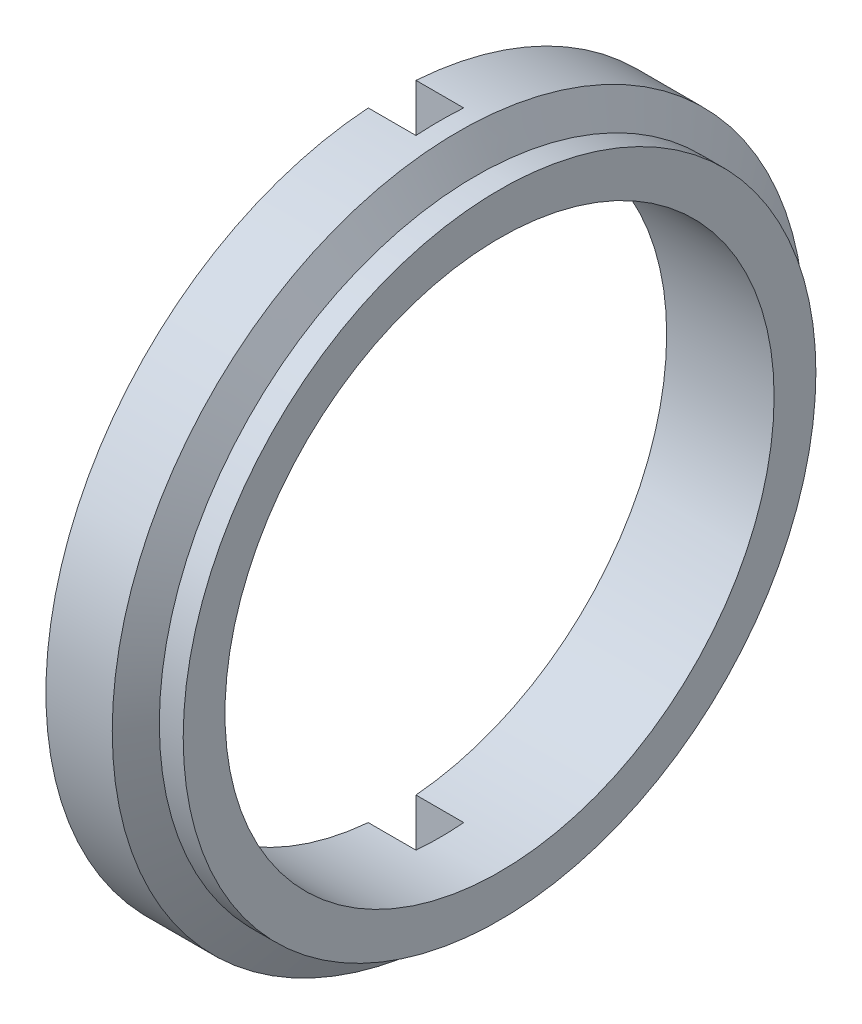
from build123d import *

# Parameters (mm, degrees)
SKETCH2_W          = 2
SKETCH2_H          = 29.895029915
CUT_EXTRUDE1_DEPTH = 2


with BuildPart() as part:
    # Sketch1 → Base-Revolve (revolve)
    with BuildSketch(Plane.XY):
        Polygon((0, 11.5), (-4.5, 11.5), (-4.5, 14.5), (-1.721687836, 14.5), (-1, 13.25), (0, 13.25), align=None)
    revolve(axis=Axis((0, 0, 0), (-1, 0, 0)))

    # Sketch2 → Cut-Extrude1 (cut)
    with BuildSketch(Plane.ZY.offset(4.5)):
        with Locations((0, -0.110232412)):
            Rectangle(SKETCH2_W, SKETCH2_H)
    extrude(amount=-CUT_EXTRUDE1_DEPTH, mode=Mode.SUBTRACT)


solid = part.part
